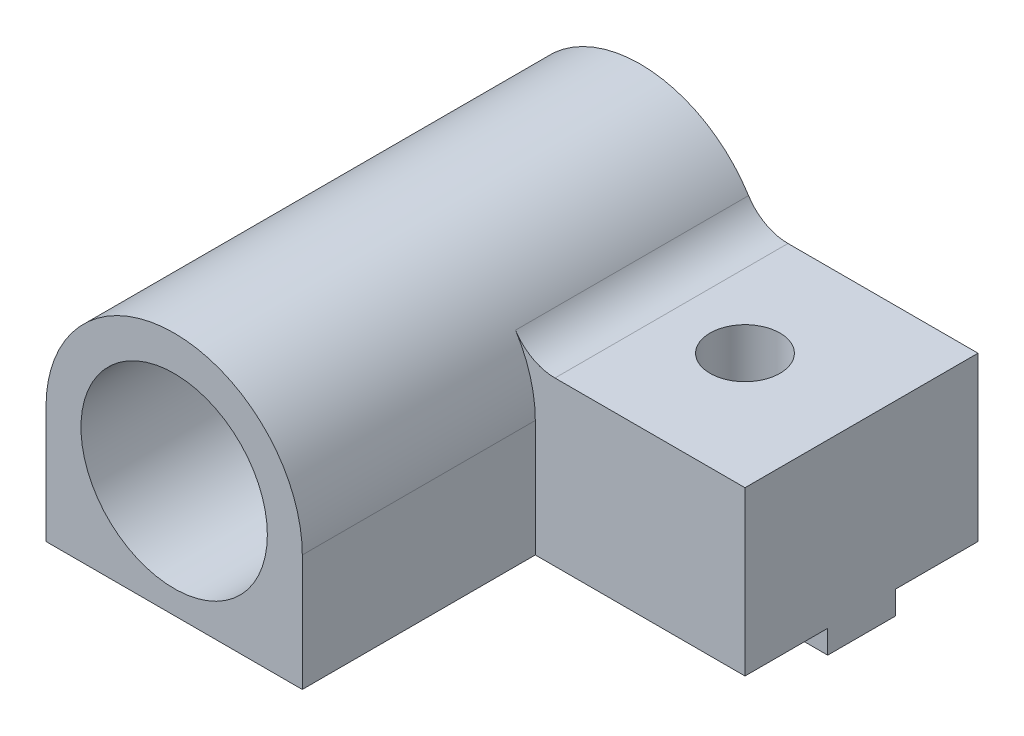
from build123d import *

# Parameters (mm, degrees)
SKETCH1_R                       = 4
MAIN_DEPTH                      = 10
SKETCH3_W                       = 20
SKETCH3_H                       = 2.9
MAKERBEAMRECTANGULARGUIDE_DEPTH = 1
SKETCH4_R                       = 1.5
MAKERBEAMFIXHOLE_DEPTH          = 9
FILLET1_R                       = 2
SKETCH5_R                       = 4
BOSS_EXTRUDE1_DEPTH             = 10


with BuildPart() as part:
    # Sketch1 → Main (new body)
    with BuildSketch(Plane.XY):
        with BuildLine():
            Line((-5.5, 0), (-5.5, -5))
            Line((-5.5, -5), (14.5, -5))
            Line((14.5, -5), (14.5, 2))
            Line((14.5, 2), (5.123475383, 2))
            ThreePointArc((5.123475383, 2), (-1.017567048, 5.405049242), (-5.5, 0))
        make_face()
        Circle(SKETCH1_R, mode=Mode.SUBTRACT)
    extrude(amount=MAIN_DEPTH)

    # Sketch3 → MakerBeamRectangularGuide (add)
    with BuildSketch(Plane(origin=(0, -5, 0), x_dir=(-1, 0, 0), z_dir=(0, -1, 0))):
        with Locations((-4.5, -5)):
            Rectangle(SKETCH3_W, SKETCH3_H)
    extrude(amount=MAKERBEAMRECTANGULARGUIDE_DEPTH)

    # Sketch4 → MakerBeamFixHole (cut, through all)
    with BuildSketch(Plane(origin=(0, 2, 0), x_dir=(1, 0, 0), z_dir=(0, 1, 0))):
        with Locations((9.5, -5)):
            Circle(SKETCH4_R)
    extrude(amount=-MAKERBEAMFIXHOLE_DEPTH, mode=Mode.SUBTRACT)

    # Fillet1
    fillet1_edges = [part.edges().sort_by_distance(p)[0] for p in [
        (5.123475383, 2, 5),
    ]]
    fillet(fillet1_edges, radius=FILLET1_R)

    # Sketch5 → Boss-Extrude1 (add)
    with BuildSketch(Plane.XY.offset(10)):
        with BuildLine():
            Line((-5.5, -5), (5.5, -5))
            Line((5.5, -5), (5.5, 0))
            ThreePointArc((5.5, 0), (0, 5.5), (-5.5, 0))
            Line((-5.5, 0), (-5.5, -5))
        make_face()
        Circle(SKETCH5_R, mode=Mode.SUBTRACT)
    extrude(amount=BOSS_EXTRUDE1_DEPTH)


solid = part.part
